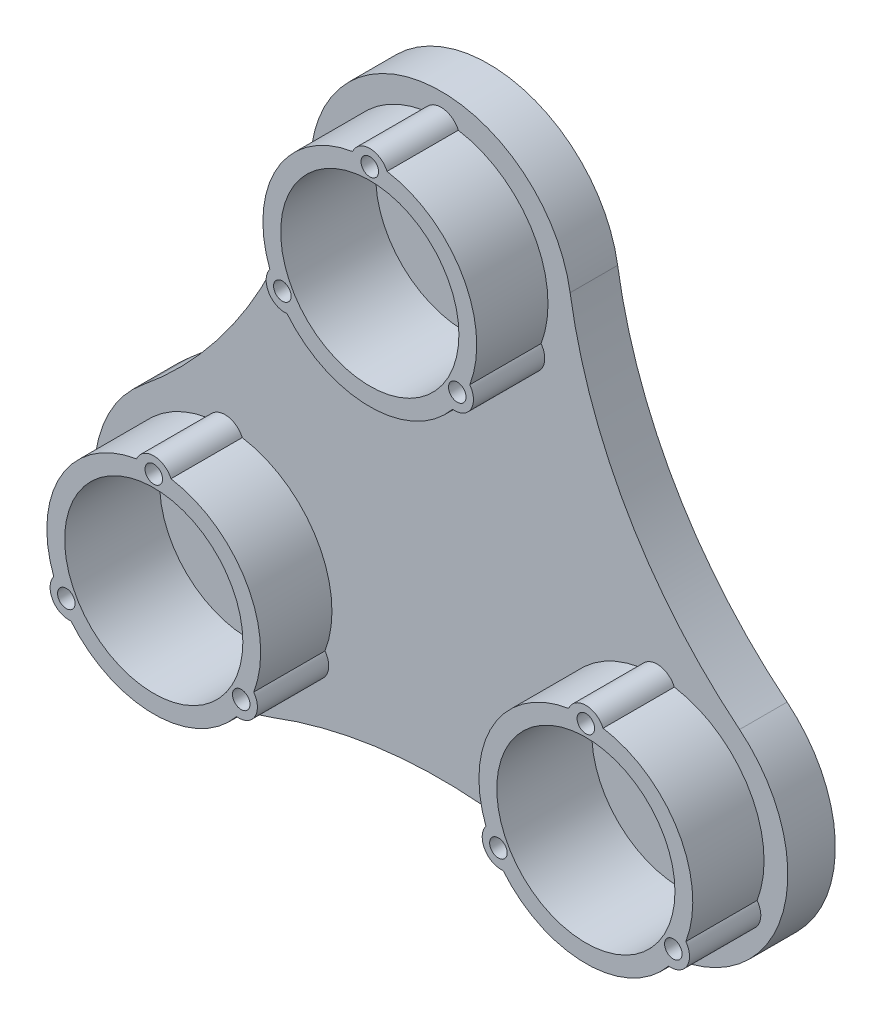
from build123d import *

# Parameters (mm, degrees)
SKETCH_1_R          = 20
SKETCH_1_R_2        = 15.75
EXTRUDE_1_DEPTH     = 5
EXTRUDE_2_DEPTH     = 8
SKETCH_3_R          = 18
EXTRUDE_3_DEPTH     = 12
EXTRUDE_6_DEPTH     = 8
SKETCH_4_R          = 15
CUT_EXTRUDE_1_DEPTH = 16
SKETCH_7_R          = 2
CUT_EXTRUDE_2_DEPTH = 10
EXTRUDE_7_REACH     = 27
SKETCH_9_R          = 1.475
CUT_EXTRUDE_3_DEPTH = 5
SKETCH_10_W         = 1.475
SKETCH_10_H         = 47.880376143
SKETCH_11_W         = 47.783072431
SKETCH_11_H         = 1.475
SKETCH_12_R         = 2
CUT_EXTRUDE_4_DEPTH = 1.5


with BuildPart() as part:
    # 草图1 → 凸台-拉伸1 (new body)
    with BuildSketch(Plane.XY):
        Circle(SKETCH_1_R)
        Circle(SKETCH_1_R_2, mode=Mode.SUBTRACT)
    extrude(amount=EXTRUDE_1_DEPTH)

    # 草图2 → 凸台-拉伸2 (add)
    with BuildSketch(Plane.XY.offset(5)):
        with BuildLine():
            ThreePointArc((0, -25.892443989), (42.435244785, -24.5), (22.423514261, 12.946221995))
            ThreePointArc((22.423514261, 12.946221995), (0, 49), (-22.423514261, 12.946221995))
            ThreePointArc((-22.423514261, 12.946221995), (-42.435244785, -24.5), (0, -25.892443989))
        make_face()
    extrude(amount=EXTRUDE_2_DEPTH)

    # 草图3 → 凸台-拉伸3 (add)
    with BuildSketch(Plane.XY.offset(13)):
        with Locations((0, 42)):
            Circle(SKETCH_3_R)
        with Locations((36.373066959, -21)):
            Circle(SKETCH_3_R)
        with Locations((-36.373066959, -21)):
            Circle(SKETCH_3_R)
    extrude(amount=EXTRUDE_3_DEPTH)

    # 草图8 → 凸台-拉伸6 (add)
    with BuildSketch(Plane(origin=(0, 0, 5), x_dir=(-1, 0, 0), z_dir=(0, 0, -1))):
        with BuildLine():
            ThreePointArc((28.527895654, -41.553668461), (55.425625842, -32), (50.250480335, -3.929048123))
            ThreePointArc((50.250480335, -3.929048123), (31.431769398, 18.147140523), (21.72258468, 45.482716583))
            ThreePointArc((21.72258468, 45.482716583), (0, 64), (-21.72258468, 45.482716583))
            ThreePointArc((-21.72258468, 45.482716583), (-31.431769398, 18.147140523), (-50.250480335, -3.929048123))
            ThreePointArc((-50.250480335, -3.929048123), (-55.425625842, -32), (-28.527895654, -41.553668461))
            ThreePointArc((-28.527895654, -41.553668461), (0, -36.294281046), (28.527895654, -41.553668461))
        make_face()
        with BuildLine():
            ThreePointArc((22.423514261, 12.946221995), (42.435244785, -24.5), (0, -25.892443989))
            ThreePointArc((0, -25.892443989), (-42.435244785, -24.5), (-22.423514261, 12.946221995))
            ThreePointArc((-22.423514261, 12.946221995), (0, 49), (22.423514261, 12.946221995))
        make_face(mode=Mode.SUBTRACT)
    extrude(amount=-EXTRUDE_6_DEPTH)

    # 草图4 → 切除-拉伸1 (cut)
    with BuildSketch(Plane.XY.offset(25)):
        with Locations((0, 42)):
            Circle(SKETCH_4_R)
        with Locations((36.373066959, -21)):
            Circle(SKETCH_4_R)
        with Locations((-36.373066959, -21)):
            Circle(SKETCH_4_R)
    extrude(amount=-CUT_EXTRUDE_1_DEPTH, mode=Mode.SUBTRACT)

    # 草图7 → 切除-拉伸2 (cut)
    with BuildSketch(Plane.XY.offset(9)):
        with Locations((0, 42)):
            Circle(SKETCH_7_R)
        with Locations((36.373066959, -21)):
            Circle(SKETCH_7_R)
        with Locations((-36.373066959, -21)):
            Circle(SKETCH_7_R)
    extrude(amount=-CUT_EXTRUDE_2_DEPTH, mode=Mode.SUBTRACT)

    # 草图6 → 凸台-拉伸7 (add, up to next)
    with BuildSketch(Plane.XY.offset(25), mode=Mode.PRIVATE) as extrude_7_sk1:
        with BuildLine():
            ThreePointArc((2.644358031, 56.765072658), (0, 61.66268909), (-2.644358031, 56.765072658))
            ThreePointArc((-2.644358031, 56.765072658), (0, 57), (2.644358031, 56.765072658))
        make_face()
    extrude_7_tool1 = extrude(extrude_7_sk1.sketch, amount=-EXTRUDE_7_REACH, mode=Mode.PRIVATE) - part.part
    add(extrude_7_tool1.solids().sort_by_distance((0, 59.041522, 25))[0])
    # 草图6 → 凸台-拉伸7 (add, up to next)
    with BuildSketch(Plane.XY.offset(25), mode=Mode.PRIVATE) as extrude_7_sk2:
        with BuildLine():
            ThreePointArc((11.464748995, 32.327382439), (17.028388258, 32.168655455), (14.109107026, 36.907544902))
            ThreePointArc((14.109107026, 36.907544902), (12.990381057, 34.5), (11.464748995, 32.327382439))
        make_face()
    extrude_7_tool2 = extrude(extrude_7_sk2.sketch, amount=-EXTRUDE_7_REACH, mode=Mode.PRIVATE) - part.part
    add(extrude_7_tool2.solids().sort_by_distance((14.758391, 33.479239, 25))[0])
    # 草图6 → 凸台-拉伸7 (add, up to next)
    with BuildSketch(Plane.XY.offset(25), mode=Mode.PRIVATE) as extrude_7_sk3:
        with BuildLine():
            ThreePointArc((-14.109107026, 36.907544902), (-17.028388258, 32.168655455), (-11.464748995, 32.327382439))
            ThreePointArc((-11.464748995, 32.327382439), (-12.990381057, 34.5), (-14.109107026, 36.907544902))
        make_face()
    extrude_7_tool3 = extrude(extrude_7_sk3.sketch, amount=-EXTRUDE_7_REACH, mode=Mode.PRIVATE) - part.part
    add(extrude_7_tool3.solids().sort_by_distance((-14.758391, 33.479239, 25))[0])
    # 草图6 → 凸台-拉伸7 (add, up to next)
    with BuildSketch(Plane.XY.offset(25), mode=Mode.PRIVATE) as extrude_7_sk4:
        with BuildLine():
            ThreePointArc((47.837815954, -30.672617561), (53.401455217, -30.831344545), (50.482173985, -26.092455098))
            ThreePointArc((50.482173985, -26.092455098), (49.363448016, -28.5), (47.837815954, -30.672617561))
        make_face()
    extrude_7_tool4 = extrude(extrude_7_sk4.sketch, amount=-EXTRUDE_7_REACH, mode=Mode.PRIVATE) - part.part
    add(extrude_7_tool4.solids().sort_by_distance((51.131457, -29.520761, 25))[0])
    # 草图6 → 凸台-拉伸7 (add, up to next)
    with BuildSketch(Plane.XY.offset(25), mode=Mode.PRIVATE) as extrude_7_sk5:
        with BuildLine():
            ThreePointArc((22.263959933, -26.092455098), (19.344678701, -30.831344545), (24.908317964, -30.672617561))
            ThreePointArc((24.908317964, -30.672617561), (23.382685902, -28.5), (22.263959933, -26.092455098))
        make_face()
    extrude_7_tool5 = extrude(extrude_7_sk5.sketch, amount=-EXTRUDE_7_REACH, mode=Mode.PRIVATE) - part.part
    add(extrude_7_tool5.solids().sort_by_distance((21.614676, -29.520761, 25))[0])
    # 草图6 → 凸台-拉伸7 (add, up to next)
    with BuildSketch(Plane.XY.offset(25), mode=Mode.PRIVATE) as extrude_7_sk6:
        with BuildLine():
            ThreePointArc((39.01742499, -6.234927342), (36.373066959, -1.33731091), (33.728708928, -6.234927342))
            ThreePointArc((33.728708928, -6.234927342), (36.373066959, -6), (39.01742499, -6.234927342))
        make_face()
    extrude_7_tool6 = extrude(extrude_7_sk6.sketch, amount=-EXTRUDE_7_REACH, mode=Mode.PRIVATE) - part.part
    add(extrude_7_tool6.solids().sort_by_distance((36.373067, -3.958478, 25))[0])
    # 草图6 → 凸台-拉伸7 (add, up to next)
    with BuildSketch(Plane.XY.offset(25), mode=Mode.PRIVATE) as extrude_7_sk7:
        with BuildLine():
            ThreePointArc((-50.482173985, -26.092455098), (-53.401455217, -30.831344545), (-47.837815954, -30.672617561))
            ThreePointArc((-47.837815954, -30.672617561), (-49.363448016, -28.5), (-50.482173985, -26.092455098))
        make_face()
    extrude_7_tool7 = extrude(extrude_7_sk7.sketch, amount=-EXTRUDE_7_REACH, mode=Mode.PRIVATE) - part.part
    add(extrude_7_tool7.solids().sort_by_distance((-51.131457, -29.520761, 25))[0])
    # 草图6 → 凸台-拉伸7 (add, up to next)
    with BuildSketch(Plane.XY.offset(25), mode=Mode.PRIVATE) as extrude_7_sk8:
        with BuildLine():
            ThreePointArc((-33.728708928, -6.234927342), (-36.373066959, -1.33731091), (-39.01742499, -6.234927342))
            ThreePointArc((-39.01742499, -6.234927342), (-36.373066959, -6), (-33.728708928, -6.234927342))
        make_face()
    extrude_7_tool8 = extrude(extrude_7_sk8.sketch, amount=-EXTRUDE_7_REACH, mode=Mode.PRIVATE) - part.part
    add(extrude_7_tool8.solids().sort_by_distance((-36.373067, -3.958478, 25))[0])
    # 草图6 → 凸台-拉伸7 (add, up to next)
    with BuildSketch(Plane.XY.offset(25), mode=Mode.PRIVATE) as extrude_7_sk9:
        with BuildLine():
            ThreePointArc((-24.908317964, -30.672617561), (-19.344678701, -30.831344545), (-22.263959933, -26.092455098))
            ThreePointArc((-22.263959933, -26.092455098), (-23.382685902, -28.5), (-24.908317964, -30.672617561))
        make_face()
    extrude_7_tool9 = extrude(extrude_7_sk9.sketch, amount=-EXTRUDE_7_REACH, mode=Mode.PRIVATE) - part.part
    add(extrude_7_tool9.solids().sort_by_distance((-21.614676, -29.520761, 25))[0])

    # 草图9 → 切除-拉伸3 (cut)
    with BuildSketch(Plane.XY.offset(25)):
        with Locations((0, 59)):
            Circle(SKETCH_9_R)
        with Locations((14.722431864, 33.5)):
            Circle(SKETCH_9_R)
        with Locations((-14.722431864, 33.5)):
            Circle(SKETCH_9_R)
        with Locations((51.095498823, -29.5)):
            Circle(SKETCH_9_R)
        with Locations((21.650635095, -29.5)):
            Circle(SKETCH_9_R)
        with Locations((36.373066959, -4)):
            Circle(SKETCH_9_R)
        with Locations((-51.095498823, -29.5)):
            Circle(SKETCH_9_R)
        with Locations((-36.373066959, -4)):
            Circle(SKETCH_9_R)
        with Locations((-21.650635095, -29.5)):
            Circle(SKETCH_9_R)
    extrude(amount=-CUT_EXTRUDE_3_DEPTH, mode=Mode.SUBTRACT)

    # 草图10 → 切除-旋转1 (revolve, cut)
    with BuildSketch(Plane(origin=(0, 0, 2.5), x_dir=(-1, 0, 0), z_dir=(0, 0, -1))):
        with Locations((0.7375, -0.269128361)):
            Rectangle(SKETCH_10_W, SKETCH_10_H)
    revolve(axis=Axis((0, 26.597082696, 2.5), (0, -1, 0)), mode=Mode.SUBTRACT)

    # 草图11 → 切除-旋转2 (revolve, cut)
    with BuildSketch(Plane(origin=(0, 0, 2.5), x_dir=(-1, 0, 0), z_dir=(0, 0, -1))):
        with Locations((0.227220258, 0.7375)):
            Rectangle(SKETCH_11_W, SKETCH_11_H)
    revolve(axis=Axis((35.344622551, 0, 2.5), (-1, 0, 0)), mode=Mode.SUBTRACT)

    # 草图12 → 切除-拉伸4 (cut)
    with BuildSketch(Plane(origin=(0, 0, 5), x_dir=(-1, 0, 0), z_dir=(0, 0, -1))):
        Polygon((-6.5, 32), (0, 32), (6.5, 32), (6.5, 60), (-6.5, 60), align=None)
        with Locations((0, 42)):
            Circle(SKETCH_12_R, mode=Mode.SUBTRACT)
        Polygon((-30.962812921, -10.370834875), (-55.211524227, -24.370834875), (-48.711524227, -35.629165125), (-24.462812921, -21.629165125), (-27.712812921, -16), align=None)
        with Locations((-36.373066959, -21)):
            Circle(SKETCH_12_R, mode=Mode.SUBTRACT)
        Polygon((24.462812921, -21.629165125), (48.711524227, -35.629165125), (55.211524227, -24.370834875), (30.962812921, -10.370834875), (27.712812921, -16), align=None)
        with Locations((36.373066959, -21)):
            Circle(SKETCH_12_R, mode=Mode.SUBTRACT)
    extrude(amount=-CUT_EXTRUDE_4_DEPTH, mode=Mode.SUBTRACT)


solid = part.part
